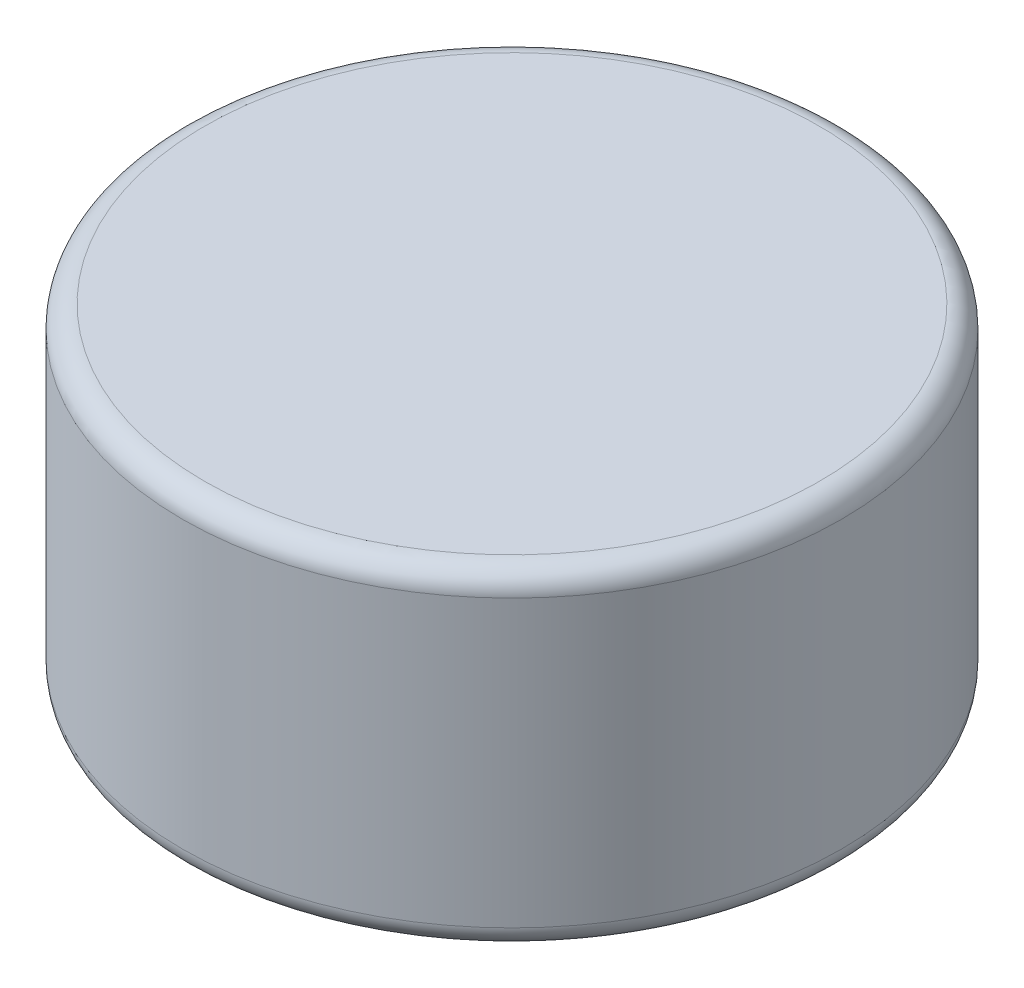
from build123d import *

# Parameters (mm, degrees)
SKETCH1_R           = 3
BOSS_EXTRUDE1_DEPTH = 3
FILLET1_R           = 0.2


with BuildPart() as part:
    # Sketch1 → Boss-Extrude1 (new body)
    with BuildSketch(Plane(origin=(0, 0, 0), x_dir=(1, 0, 0), z_dir=(0, 1, 0))):
        Circle(SKETCH1_R)
    extrude(amount=BOSS_EXTRUDE1_DEPTH)

    # Fillet1
    fillet1_edges = [part.edges().sort_by_distance(p)[0] for p in [
        (-3, 0, 0),
        (-3, 3, 0),
    ]]
    fillet(fillet1_edges, radius=FILLET1_R)


solid = part.part
